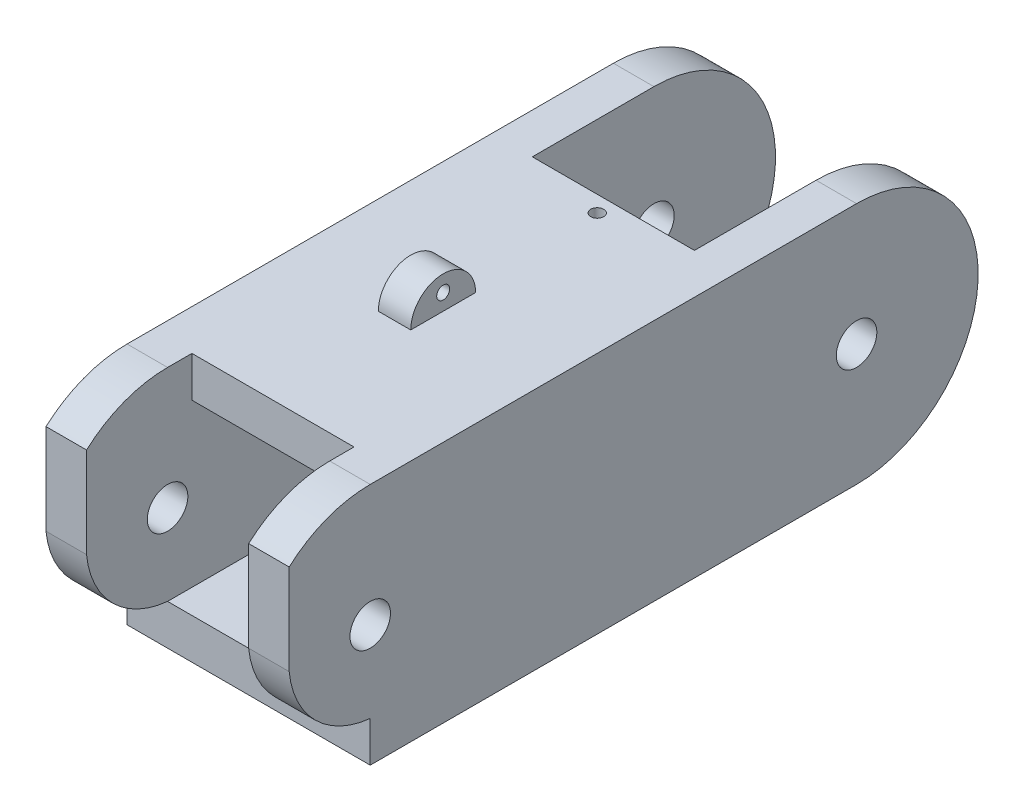
from build123d import *

# Parameters (mm, degrees)
SKETCH1_W           = 19.05
SKETCH1_H           = 57.15
BOSS_EXTRUDE1_DEPTH = 19.05
SKETCH2_W           = 12.7
SKETCH2_H           = 12.7
CUT_EXTRUDE1_DEPTH  = 76.2
SKETCH3_W           = 2.54
SKETCH3_H           = 5.08
BOSS_EXTRUDE2_DEPTH = 2.54
SKETCH4_R           = 0.508
SKETCH4_R_2         = 1.5875
CUT_EXTRUDE2_DEPTH  = 19.05
SKETCH7_R           = 0.508
CUT_EXTRUDE3_DEPTH  = 12.7
SKETCH8_W           = 12.7
SKETCH8_H           = 9.525
CUT_EXTRUDE4_DEPTH  = 25.4
SKETCH11_R          = 1.5875
CUT_EXTRUDE6_DEPTH  = 19.05
SKETCH12_W          = 12.7
SKETCH12_H          = 30.970960978
CUT_EXTRUDE7_DEPTH  = 3.81
SKETCH13_W          = 12.7
SKETCH13_H          = 19.463069007
CUT_EXTRUDE8_DEPTH  = 3.81
CUT_EXTRUDE9_DEPTH  = 19.05


with BuildPart() as part:
    # Sketch1 → Boss-Extrude1 (new body)
    with BuildSketch(Plane(origin=(0, 0, 0), x_dir=(1, 0, 0), z_dir=(0, 1, 0))):
        with Locations((9.525, 28.575)):
            Rectangle(SKETCH1_W, SKETCH1_H)
    extrude(amount=BOSS_EXTRUDE1_DEPTH)

    # Sketch2 → Cut-Extrude1 (cut)
    with BuildSketch(Plane.XY):
        with Locations((9.525, 9.525)):
            Rectangle(SKETCH2_W, SKETCH2_H)
    extrude(amount=-CUT_EXTRUDE1_DEPTH, mode=Mode.SUBTRACT)

    # Sketch3 → Boss-Extrude2 (add)
    with BuildSketch(Plane(origin=(0, 19.05, 0), x_dir=(1, 0, 0), z_dir=(0, 1, 0))):
        with Locations((8.89, 24.13)):
            Rectangle(SKETCH3_W, SKETCH3_H)
    extrude(amount=BOSS_EXTRUDE2_DEPTH)

    # Sketch4 → Cut-Extrude2 (cut)
    with BuildSketch(Plane(origin=(0, 0, 0), x_dir=(0, 0, -1), z_dir=(1, 0, 0))):
        with Locations((24.13, 20.32)):
            Circle(SKETCH4_R)
        with Locations((9.525, 9.525)):
            Circle(SKETCH4_R_2)
        with BuildLine():
            ThreePointArc((26.67, 19.05), (24.13, 24.78976855), (21.59, 19.05))
            add(Edge.make_bspline(
                [(26.67, 19.05), (26.67, 21.59), (24.13, 21.59), (21.59, 21.59), (21.59, 19.05)],
                knots=[3.141592654, 3.141592654, 3.141592654, 4.71238898, 4.71238898, 6.283185307, 6.283185307, 6.283185307], degree=2, weights=[1, 0.707106781, 1, 0.707106781, 1]))
        make_face()
        with BuildLine():
            ThreePointArc((9.525, 19.05), (0, 9.525), (9.525, 0))
            ThreePointArc((9.525, 0), (-29.420443119, 9.525), (9.525, 19.05))
        make_face()
    extrude(amount=CUT_EXTRUDE2_DEPTH, mode=Mode.SUBTRACT)

    # Sketch7 → Cut-Extrude3 (cut)
    with BuildSketch(Plane(origin=(0, 19.05, 0), x_dir=(1, 0, 0), z_dir=(0, 1, 0))):
        with Locations((9.525, 36.83)):
            Circle(SKETCH7_R)
        Polygon((3.175, 0), (3.175, 11.43), (6.35, 11.43), (12.7, 11.43), (15.875, 11.43), (15.875, 0), align=None)
    extrude(amount=-CUT_EXTRUDE3_DEPTH, mode=Mode.SUBTRACT)

    # Sketch8 → Cut-Extrude4 (cut)
    with BuildSketch(Plane(origin=(0, 19.05, 0), x_dir=(1, 0, 0), z_dir=(0, 1, 0))):
        with Locations((9.525, 4.7625)):
            Rectangle(SKETCH8_W, SKETCH8_H)
    extrude(amount=-CUT_EXTRUDE4_DEPTH, mode=Mode.SUBTRACT)

    # Sketch11 → Cut-Extrude6 (cut)
    with BuildSketch(Plane(origin=(0, 0, 0), x_dir=(0, 0, -1), z_dir=(1, 0, 0))):
        with Locations((47.625, 9.525)):
            Circle(SKETCH11_R)
        with BuildLine():
            ThreePointArc((47.625, 0), (57.15, 9.525), (47.625, 19.05))
            ThreePointArc((47.625, 19.05), (63.905355935, 9.525), (47.625, 0))
        make_face()
    extrude(amount=CUT_EXTRUDE6_DEPTH, mode=Mode.SUBTRACT)

    # Sketch12 → Cut-Extrude7 (cut)
    with BuildSketch(Plane(origin=(0, 19.05, 0), x_dir=(1, 0, 0), z_dir=(0, 1, 0))):
        with Locations((9.525, 53.585480489)):
            Rectangle(SKETCH12_W, SKETCH12_H)
    extrude(amount=-CUT_EXTRUDE7_DEPTH, mode=Mode.SUBTRACT)

    # Sketch13 → Cut-Extrude8 (cut)
    with BuildSketch(Plane(origin=(0, 0, 0), x_dir=(1, 0, 0), z_dir=(0, 1, 0))):
        with Locations((9.525, 57.356534504)):
            Rectangle(SKETCH13_W, SKETCH13_H)
    extrude(amount=CUT_EXTRUDE8_DEPTH, mode=Mode.SUBTRACT)

    # Sketch14 → Cut-Extrude9 (cut)
    with BuildSketch(Plane(origin=(0, 0, 0), x_dir=(0, 0, -1), z_dir=(1, 0, 0))):
        with BuildLine():
            Line((9.525, 0), (9.525, 3.175))
            ThreePointArc((9.525, 3.175), (5.21507822, 5.21507822), (3.175, 9.525))
            Line((3.175, 9.525), (3.175, 18.741336737))
            Line((3.175, 18.741336737), (-3.728591213, 9.978700773))
            Line((-3.728591213, 9.978700773), (-2.544461104, 0))
            Line((-2.544461104, 0), (9.525, 0))
        make_face()
    extrude(amount=CUT_EXTRUDE9_DEPTH, mode=Mode.SUBTRACT)


solid = part.part
